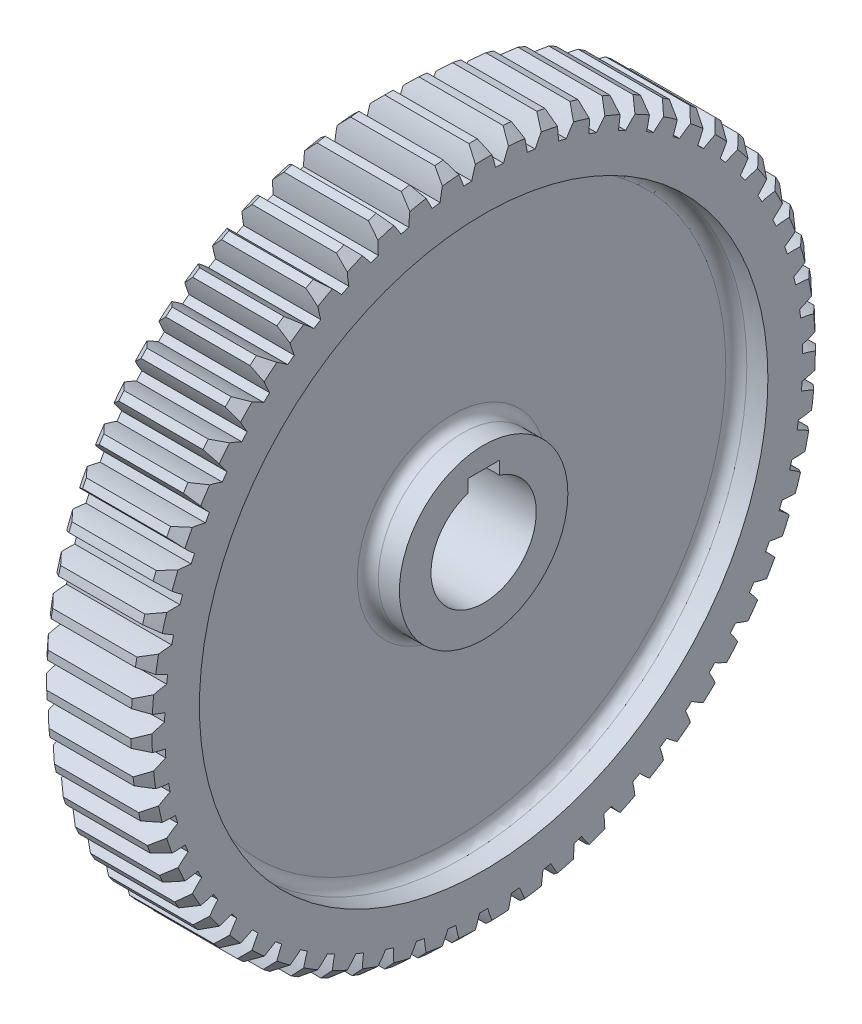
from build123d import *

# Parameters (mm, degrees)
CHAMFER_1_SIZE           = 2
CUT_EXTRUDE1_DEPTH       = 50
CIRPATTERN2_COUNT        = 63
FILLET_1_R               = 2
SKETCH_3_W               = 6
SKETCH_3_H               = 12
CUT_EXTRUDE_1_DEPTH      = 11.0000001
CUT_EXTRUDE_1_DEPTH_BACK = 11.0000001


with BuildPart() as part:
    # Эскиз1 → Повернуть1 (revolve)
    with BuildSketch(Plane.XY):
        Polygon((-10, 10), (10, 10), (10, 16), (4, 16), (4, 54), (10, 54), (10, 65), (-10, 65), (-10, 54), (-4, 54), (-4, 16), (-10, 16), align=None)
    revolve(axis=Axis((0, 0, 0), (-1, 0, 0)))

    # Фаска1
    chamfer_1_edges = [part.edges().sort_by_distance(p)[0] for p in [
        (-10, -65, 0),
        (10, -65, 0),
    ]]
    chamfer(chamfer_1_edges, length=CHAMFER_1_SIZE)

    # Sketch3 → Cut-Extrude1-Впадина зуба (cut)
    with BuildSketch(Plane(origin=(10, 9.497828625, -4.336443521), x_dir=(0, 0, -1), z_dir=(1, 0, 0))):
        with BuildLine():
            ThreePointArc((-2.084496965, 51.060314813), (-2.709366812, 53.312596643), (-3.540228214, 55.497294586))
            ThreePointArc((-3.540228214, 55.497294586), (-1.096460953, 55.421371254), (1.342722201, 55.253596662))
            ThreePointArc((1.342722201, 55.253596662), (0.298463867, 53.162482055), (-0.547555714, 50.983609264))
            ThreePointArc((-0.547555714, 50.983609264), (-1.31578285, 51.026840801), (-2.084496965, 51.060314813))
        make_face()
    cut_extrude1 = extrude(amount=-CUT_EXTRUDE1_DEPTH, mode=Mode.SUBTRACT)

    # CirPattern2: Cut-Extrude1-Впадина зуба ×63 about axis
    cirpattern2_axis = Axis((0, 0, 0), (1, 0, 0))
    for i in range(1, CIRPATTERN2_COUNT):
        add(cut_extrude1.rotate(cirpattern2_axis, i * 360 / CIRPATTERN2_COUNT), mode=Mode.SUBTRACT)

    # Скругление1
    fillet_1_edges = [part.edges().sort_by_distance(p)[0] for p in [
        (4, -54, 0),
        (4, -16, 0),
        (-4, -16, 0),
        (-4, -54, 0),
    ]]
    fillet(fillet_1_edges, radius=FILLET_1_R)

    # Эскиз3 → Вырез-Вытянуть1 (cut, two sides)
    with BuildSketch(Plane(origin=(0, 0, 0), x_dir=(0, 0, -1), z_dir=(1, 0, 0))) as cut_extrude_1_sk:
        with Locations((0, 6)):
            Rectangle(SKETCH_3_W, SKETCH_3_H)
    extrude(amount=CUT_EXTRUDE_1_DEPTH, mode=Mode.SUBTRACT)
    extrude(cut_extrude_1_sk.sketch, amount=-CUT_EXTRUDE_1_DEPTH_BACK, mode=Mode.SUBTRACT)


solid = part.part
